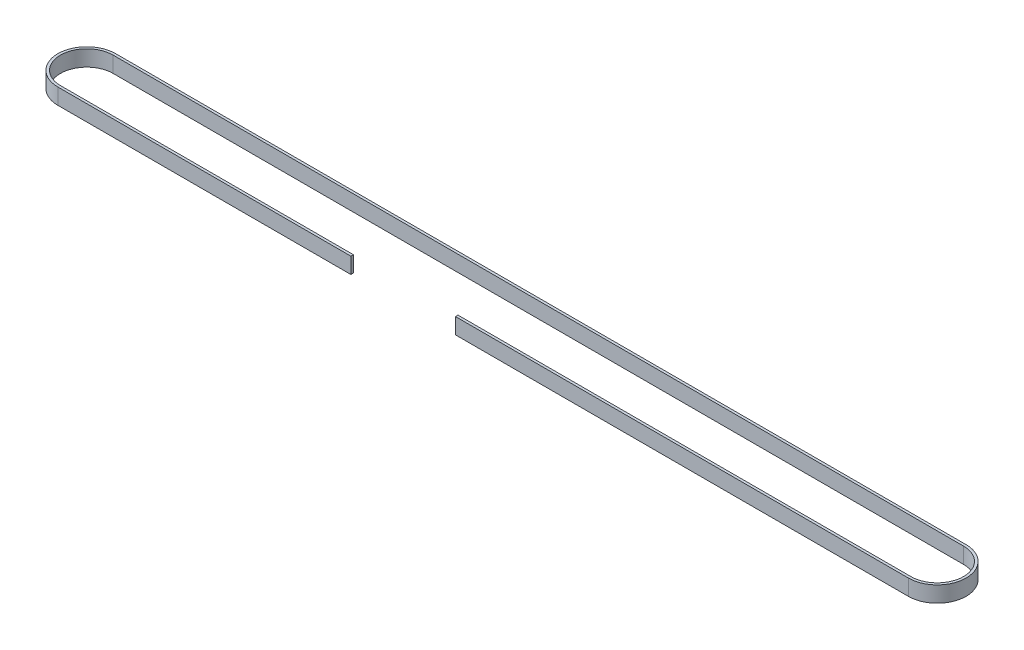
from build123d import *

# Parameters (mm, degrees)
BOSS_EXTRUDE1_DEPTH = 9.652
SKETCH2_W           = 63.5
SKETCH2_H           = 9.652
CUT_EXTRUDE1_DEPTH  = 12.7


with BuildPart() as part:
    # Sketch1 → Boss-Extrude1 (new body)
    with BuildSketch(Plane(origin=(0, 0, 0), x_dir=(1, 0, 0), z_dir=(0, 1, 0))):
        with BuildLine():
            Line((0, 17.78), (516.128, 17.78))
            ThreePointArc((516.128, 17.78), (533.654, 0.254), (516.128, -17.272))
            Line((516.128, -17.272), (0, -17.272))
            ThreePointArc((0, -17.272), (-17.526, 0.254), (0, 17.78))
        make_face()
        with BuildLine():
            Line((0, 16.256), (516.128, 16.256))
            ThreePointArc((516.128, 16.256), (532.13, 0.254), (516.128, -15.748))
            Line((516.128, -15.748), (0, -15.748))
            ThreePointArc((0, -15.748), (-16.002, 0.254), (0, 16.256))
        make_face(mode=Mode.SUBTRACT)
    extrude(amount=BOSS_EXTRUDE1_DEPTH)

    # Sketch2 → Cut-Extrude1 (cut)
    with BuildSketch(Plane.XY.offset(17.272)):
        with Locations((209.55, 4.826)):
            Rectangle(SKETCH2_W, SKETCH2_H)
    extrude(amount=-CUT_EXTRUDE1_DEPTH, mode=Mode.SUBTRACT)


solid = part.part
